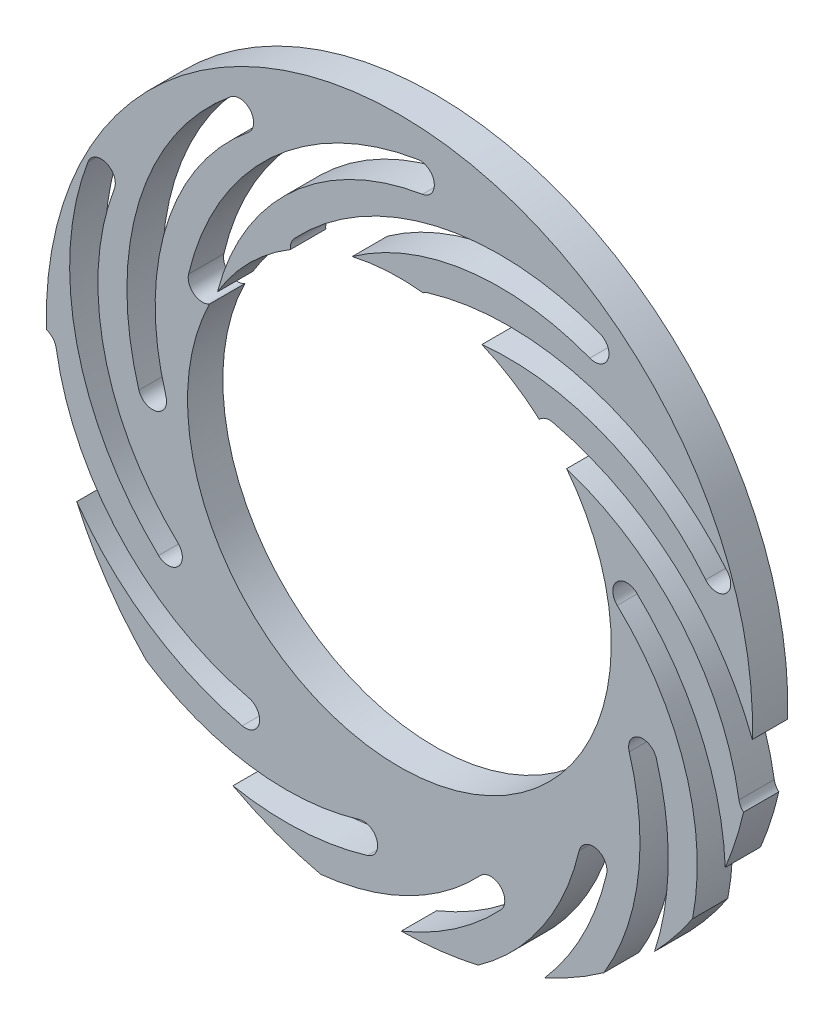
from build123d import *

# Parameters (mm, degrees)
SKETCH4_R           = 5
SKETCH4_R_2         = 3
BOSS_EXTRUDE2_DEPTH = 0.5
CUT_EXTRUDE1_DEPTH  = 0.5


with BuildPart() as part:
    # Sketch4 → Boss-Extrude2 (new body)
    with BuildSketch(Plane.XY):
        Circle(SKETCH4_R)
        Circle(SKETCH4_R_2, mode=Mode.SUBTRACT)
    extrude(amount=BOSS_EXTRUDE2_DEPTH)

    # Sketch5 → Cut-Extrude1 (cut)
    with BuildSketch(Plane.XY):
        with BuildLine():
            ThreePointArc((2.838380277, 3.735395811), (0.523052201, 3.89223631), (-1.488789119, 2.735587034))
            ThreePointArc((-1.488789119, 2.735587034), (-1.479999142, 2.452880939), (-1.197293047, 2.461670915))
            ThreePointArc((-1.197293047, 2.461670915), (0.613101285, 3.502504142), (2.696594047, 3.361368186))
            ThreePointArc((2.696594047, 3.361368186), (2.954500975, 3.477488883), (2.838380277, 3.735395811))
        make_face()
        with BuildLine():
            ThreePointArc((4.336939093, 1.463159243), (2.603149411, 2.627132948), (0.514885315, 2.630942098))
            ThreePointArc((0.514885315, 2.630942098), (0.265659666, 2.764682803), (0.399400371, 3.013908452))
            ThreePointArc((0.399400371, 3.013908452), (2.7200307, 3.009675448), (4.646743383, 1.716183554))
            ThreePointArc((4.646743383, 1.716183554), (4.618353394, 1.434769253), (4.336939093, 1.463159243))
        make_face()
        with BuildLine():
            ThreePointArc((4.808415103, -1.000910445), (3.888896046, 0.874015193), (2.082310864, 1.921446063))
            ThreePointArc((2.082310864, 1.921446063), (1.933345473, 2.161881735), (2.173781146, 2.310847125))
            ThreePointArc((2.173781146, 2.310847125), (4.181389462, 1.146866072), (5.203225644, -0.93668711))
            ThreePointArc((5.203225644, -0.93668711), (5.037932041, -1.166204048), (4.808415103, -1.000910445))
        make_face()
        with BuildLine():
            ThreePointArc((3.98469046, -3.370595397), (4.125826417, -1.287102636), (3.08499319, 0.523291697))
            ThreePointArc((3.08499319, 0.523291697), (3.076203214, 0.805997792), (3.358909309, 0.814787769))
            ThreePointArc((3.358909309, 0.814787769), (4.515558585, -1.197053551), (4.358718086, -3.512381628))
            ThreePointArc((4.358718086, -3.512381628), (4.100811158, -3.628502325), (3.98469046, -3.370595397))
        make_face()
        with BuildLine():
            ThreePointArc((2.086481518, -5.010940443), (3.250455223, -3.277150761), (3.254264373, -1.188886665))
            ThreePointArc((3.254264373, -1.188886665), (3.388005078, -0.939661016), (3.637230727, -1.073401721))
            ThreePointArc((3.637230727, -1.073401721), (3.632997723, -3.394032051), (2.339505829, -5.320744734))
            ThreePointArc((2.339505829, -5.320744734), (2.058091528, -5.292354744), (2.086481518, -5.010940443))
        make_face()
        with BuildLine():
            ThreePointArc((-0.37758817, -5.482416453), (1.497337468, -4.562897396), (2.544768337, -2.756312214))
            ThreePointArc((2.544768337, -2.756312214), (2.78520401, -2.607346824), (2.9341694, -2.847782496))
            ThreePointArc((2.9341694, -2.847782496), (1.770188347, -4.855390812), (-0.313364835, -5.877226994))
            ThreePointArc((-0.313364835, -5.877226994), (-0.542881773, -5.711933391), (-0.37758817, -5.482416453))
        make_face()
        with BuildLine():
            ThreePointArc((-2.747273122, -4.658691811), (-0.663780361, -4.799827767), (1.146613972, -3.75899454))
            ThreePointArc((1.146613972, -3.75899454), (1.429320067, -3.750204564), (1.438110043, -4.032910659))
            ThreePointArc((1.438110043, -4.032910659), (-0.573731276, -5.189559935), (-2.889059353, -5.032719436))
            ThreePointArc((-2.889059353, -5.032719436), (-3.00518005, -4.774812508), (-2.747273122, -4.658691811))
        make_face()
        with BuildLine():
            ThreePointArc((-4.387618168, -2.760482868), (-2.653828487, -3.924456573), (-0.56556439, -3.928265723))
            ThreePointArc((-0.56556439, -3.928265723), (-0.316338742, -4.062006428), (-0.450079446, -4.311232077))
            ThreePointArc((-0.450079446, -4.311232077), (-2.770709776, -4.306999073), (-4.697422459, -3.013507179))
            ThreePointArc((-4.697422459, -3.013507179), (-4.669032469, -2.732092879), (-4.387618168, -2.760482868))
        make_face()
        with BuildLine():
            ThreePointArc((-4.859094178, -0.29641318), (-3.939575121, -2.171338818), (-2.132989939, -3.218769688))
            ThreePointArc((-2.132989939, -3.218769688), (-1.984024549, -3.45920536), (-2.224460221, -3.60817075))
            ThreePointArc((-2.224460221, -3.60817075), (-4.232068537, -2.444189697), (-5.253904719, -0.360636515))
            ThreePointArc((-5.253904719, -0.360636515), (-5.088611116, -0.131119577), (-4.859094178, -0.29641318))
        make_face()
        with BuildLine():
            ThreePointArc((-4.035369536, 2.073271772), (-4.176505492, -0.01022099), (-3.135672265, -1.820615322))
            ThreePointArc((-3.135672265, -1.820615322), (-3.126882289, -2.103321417), (-3.409588384, -2.112111394))
            ThreePointArc((-3.409588384, -2.112111394), (-4.56623766, -0.100270074), (-4.409397161, 2.215058003))
            ThreePointArc((-4.409397161, 2.215058003), (-4.151490233, 2.3311787), (-4.035369536, 2.073271772))
        make_face()
        with BuildLine():
            ThreePointArc((-2.137160594, 3.713616818), (-3.301134298, 1.979827136), (-3.304943449, -0.10843696))
            ThreePointArc((-3.304943449, -0.10843696), (-3.438684153, -0.357662609), (-3.687909802, -0.223921904))
            ThreePointArc((-3.687909802, -0.223921904), (-3.683676798, 2.096708426), (-2.390184904, 4.023421109))
            ThreePointArc((-2.390184904, 4.023421109), (-2.108770604, 3.995031119), (-2.137160594, 3.713616818))
        make_face()
        with BuildLine():
            ThreePointArc((0.326909095, 4.185092828), (-1.548016544, 3.265573771), (-2.595447413, 1.458988589))
            ThreePointArc((-2.595447413, 1.458988589), (-2.835883085, 1.310023199), (-2.984848475, 1.550458871))
            ThreePointArc((-2.984848475, 1.550458871), (-1.820867422, 3.558067187), (0.26268576, 4.579903369))
            ThreePointArc((0.26268576, 4.579903369), (0.492202698, 4.414609766), (0.326909095, 4.185092828))
        make_face()
    extrude(amount=CUT_EXTRUDE1_DEPTH, mode=Mode.SUBTRACT)


solid = part.part
